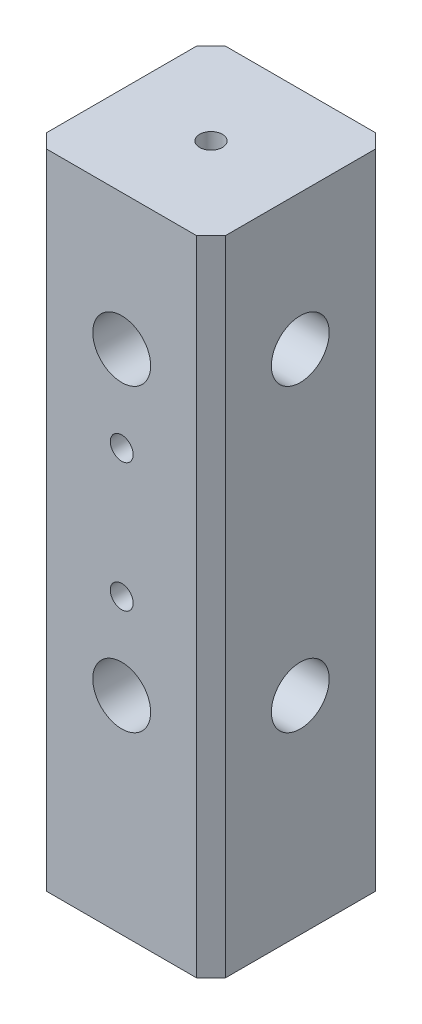
from build123d import *

# Parameters (mm, degrees)
SKETCH1_W           = 25
SKETCH1_H           = 25
BOSS_EXTRUDE1_DEPTH = 90
SKETCH2_R           = 4.05
CUT_EXTRUDE1_DEPTH  = 8
SKETCH3_R           = 4.05
CUT_EXTRUDE7_DEPTH  = 8
CHAMFER1_SIZE       = 2
SKETCH5_R           = 1.6
CUT_EXTRUDE8_DEPTH  = 12.5
SKETCH6_R           = 1.6
CUT_EXTRUDE9_DEPTH  = 10


with BuildPart() as part:
    # Sketch1 → Boss-Extrude1 (new body)
    with BuildSketch(Plane(origin=(0, 0, 0), x_dir=(1, 0, 0), z_dir=(0, 1, 0))):
        Rectangle(SKETCH1_W, SKETCH1_H)
    extrude(amount=BOSS_EXTRUDE1_DEPTH)

    # Sketch2 → Cut-Extrude1 (cut)
    with BuildSketch(Plane(origin=(12.5, 0, 0), x_dir=(0, 0, -1), z_dir=(1, 0, 0))):
        with Locations((0, 71)):
            Circle(SKETCH2_R)
        with Locations((0, 29)):
            Circle(SKETCH2_R)
    extrude(amount=-CUT_EXTRUDE1_DEPTH, mode=Mode.SUBTRACT)

    # Sketch3 → Cut-Extrude7 (cut)
    with BuildSketch(Plane.XY.offset(12.5)):
        with Locations((0, 29)):
            Circle(SKETCH3_R)
        with Locations((0, 71)):
            Circle(SKETCH3_R)
    extrude(amount=-CUT_EXTRUDE7_DEPTH, mode=Mode.SUBTRACT)

    # Chamfer1
    chamfer1_edges = [part.edges().sort_by_distance(p)[0] for p in [
        (12.5, 45, 12.5),
        (-12.5, 45, 12.5),
        (-12.5, 45, -12.5),
        (12.5, 45, -12.5),
    ]]
    chamfer(chamfer1_edges, length=CHAMFER1_SIZE)

    # Sketch5 → Cut-Extrude8 (cut)
    with BuildSketch(Plane.XY.offset(12.5)):
        with Locations((0, 59)):
            Circle(SKETCH5_R)
        with Locations((0, 41)):
            Circle(SKETCH5_R)
    extrude(amount=-CUT_EXTRUDE8_DEPTH, mode=Mode.SUBTRACT)

    # Sketch6 → Cut-Extrude9 (cut)
    with BuildSketch(Plane(origin=(0, 90, 0), x_dir=(1, 0, 0), z_dir=(0, 1, 0))):
        Circle(SKETCH6_R)
    extrude(amount=-CUT_EXTRUDE9_DEPTH, mode=Mode.SUBTRACT)


solid = part.part
